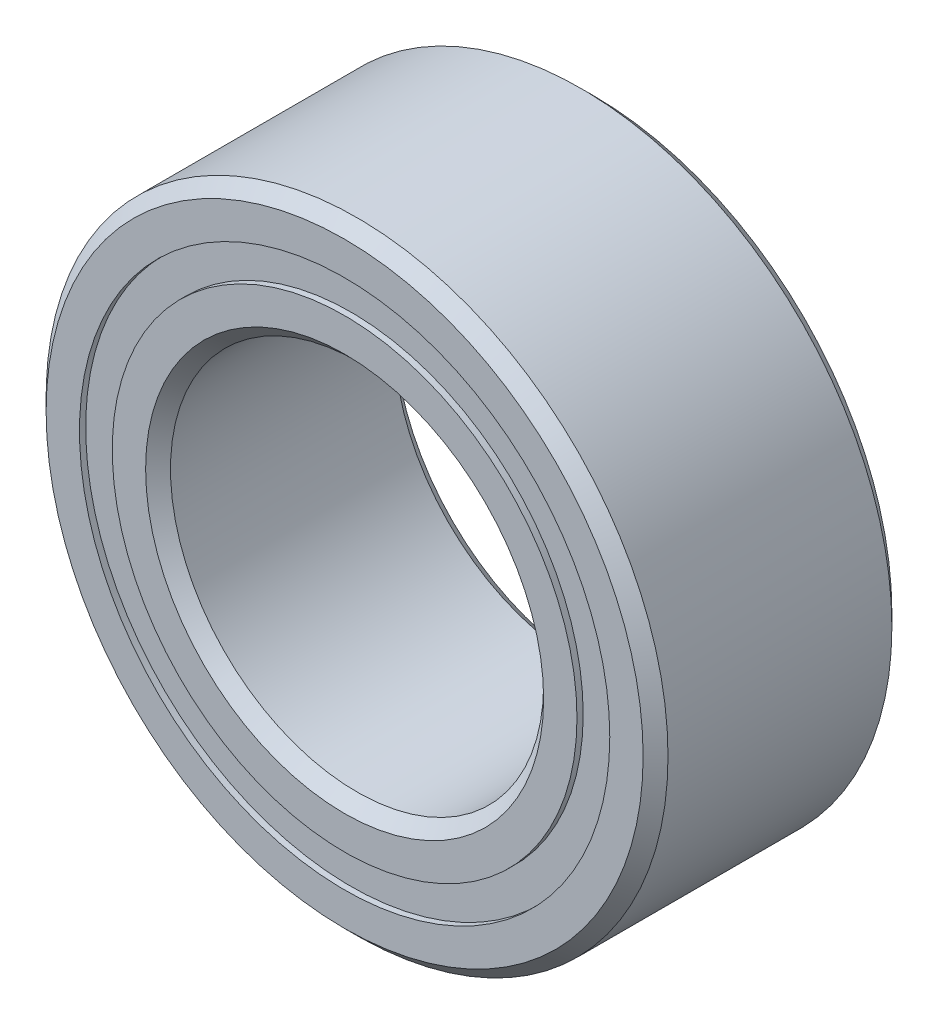
from build123d import *

# Parameters (mm, degrees)
CIRPATTERN1_COUNT = 12
SKETCH5_W         = 0.772168375
SKETCH5_H         = 0.418681318


with BuildPart() as part:
    # Sketch1 → Revolve1 (revolve)
    with BuildSketch(Plane(origin=(0, 0, 0), x_dir=(0, 0, -1), z_dir=(1, 0, 0))):
        with BuildLine():
            Line((1.42875, 3.96875), (-1.42875, 3.96875))
            Line((-1.42875, 3.96875), (-1.5875, 3.81))
            Line((-1.5875, 3.81), (-1.5875, 3.384340659))
            Line((-1.5875, 3.384340659), (-0.705555556, 3.384340659))
            ThreePointArc((-0.705555556, 3.384340659), (0, 3.910956625), (0.705555556, 3.384340659))
            Line((0.705555556, 3.384340659), (1.5875, 3.384340659))
            Line((1.5875, 3.384340659), (1.5875, 3.81))
            Line((1.5875, 3.81), (1.42875, 3.96875))
        make_face()
    revolve(axis=Axis((0, 0, 1.5875), (0, 0, -1)))


with BuildPart() as body_2:
    # Sketch3 → Revolve3 (revolve)
    with BuildSketch(Plane(origin=(0, 0, 0), x_dir=(0, 0, -1), z_dir=(1, 0, 0))):
        with BuildLine():
            Line((-0.705555556, 2.965659341), (-1.5875, 2.965659341))
            Line((-1.5875, 2.965659341), (-1.5875, 2.54))
            Line((-1.5875, 2.54), (-1.42875, 2.38125))
            Line((-1.42875, 2.38125), (1.42875, 2.38125))
            Line((1.42875, 2.38125), (1.5875, 2.54))
            Line((1.5875, 2.54), (1.5875, 2.965659341))
            Line((1.5875, 2.965659341), (0.705555556, 2.965659341))
            ThreePointArc((0.705555556, 2.965659341), (0, 2.439043375), (-0.705555556, 2.965659341))
        make_face()
    revolve(axis=Axis((0, 0, 1.5875), (0, 0, -1)))


with BuildPart() as body_3:
    # Sketch4 → Revolve4 (revolve)
    with BuildSketch(Plane(origin=(0, 0, 0), x_dir=(0, 0, -1), z_dir=(1, 0, 0))):
        with BuildLine():
            Line((-0.735956625, 3.175), (0.735956625, 3.175))
            ThreePointArc((0.735956625, 3.175), (0, 3.910956625), (-0.735956625, 3.175))
        make_face()
    revolve(axis=Axis((0, 3.175, 0.735956625), (0, 0, -1)))


with BuildPart() as cirpattern1_1:
    # CirPattern1: pattern copy
    add(body_3.part.rotate(Axis((0, 0, -1.5875), (0, 0, 1)), 1 * 360 / CIRPATTERN1_COUNT))


with BuildPart() as cirpattern1_2:
    # CirPattern1: pattern copy
    add(body_3.part.rotate(Axis((0, 0, -1.5875), (0, 0, 1)), 2 * 360 / CIRPATTERN1_COUNT))


with BuildPart() as cirpattern1_3:
    # CirPattern1: pattern copy
    add(body_3.part.rotate(Axis((0, 0, -1.5875), (0, 0, 1)), 3 * 360 / CIRPATTERN1_COUNT))


with BuildPart() as cirpattern1_4:
    # CirPattern1: pattern copy
    add(body_3.part.rotate(Axis((0, 0, -1.5875), (0, 0, 1)), 4 * 360 / CIRPATTERN1_COUNT))


with BuildPart() as cirpattern1_5:
    # CirPattern1: pattern copy
    add(body_3.part.rotate(Axis((0, 0, -1.5875), (0, 0, 1)), 5 * 360 / CIRPATTERN1_COUNT))


with BuildPart() as cirpattern1_6:
    # CirPattern1: pattern copy
    add(body_3.part.rotate(Axis((0, 0, -1.5875), (0, 0, 1)), 6 * 360 / CIRPATTERN1_COUNT))


with BuildPart() as cirpattern1_7:
    # CirPattern1: pattern copy
    add(body_3.part.rotate(Axis((0, 0, -1.5875), (0, 0, 1)), 7 * 360 / CIRPATTERN1_COUNT))


with BuildPart() as cirpattern1_8:
    # CirPattern1: pattern copy
    add(body_3.part.rotate(Axis((0, 0, -1.5875), (0, 0, 1)), 8 * 360 / CIRPATTERN1_COUNT))


with BuildPart() as cirpattern1_9:
    # CirPattern1: pattern copy
    add(body_3.part.rotate(Axis((0, 0, -1.5875), (0, 0, 1)), 9 * 360 / CIRPATTERN1_COUNT))


with BuildPart() as cirpattern1_10:
    # CirPattern1: pattern copy
    add(body_3.part.rotate(Axis((0, 0, -1.5875), (0, 0, 1)), 10 * 360 / CIRPATTERN1_COUNT))


with BuildPart() as cirpattern1_11:
    # CirPattern1: pattern copy
    add(body_3.part.rotate(Axis((0, 0, -1.5875), (0, 0, 1)), 11 * 360 / CIRPATTERN1_COUNT))


with BuildPart() as body_15:
    # Sketch5 → Revolve5 (revolve)
    with BuildSketch(Plane(origin=(0, 0, 0), x_dir=(0, 0, -1), z_dir=(1, 0, 0))):
        with Locations((-1.122040813, 3.175)):
            Rectangle(SKETCH5_W, SKETCH5_H)
        with Locations((1.122040813, 3.175)):
            Rectangle(SKETCH5_W, SKETCH5_H)
    revolve(axis=Axis((0, 0, 1.5875), (0, 0, -1)))


solid = Compound([part.part, body_2.part, body_3.part, cirpattern1_1.part, cirpattern1_2.part, cirpattern1_3.part, cirpattern1_4.part, cirpattern1_5.part, cirpattern1_6.part, cirpattern1_7.part, cirpattern1_8.part, cirpattern1_9.part, cirpattern1_10.part, cirpattern1_11.part, body_15.part])
